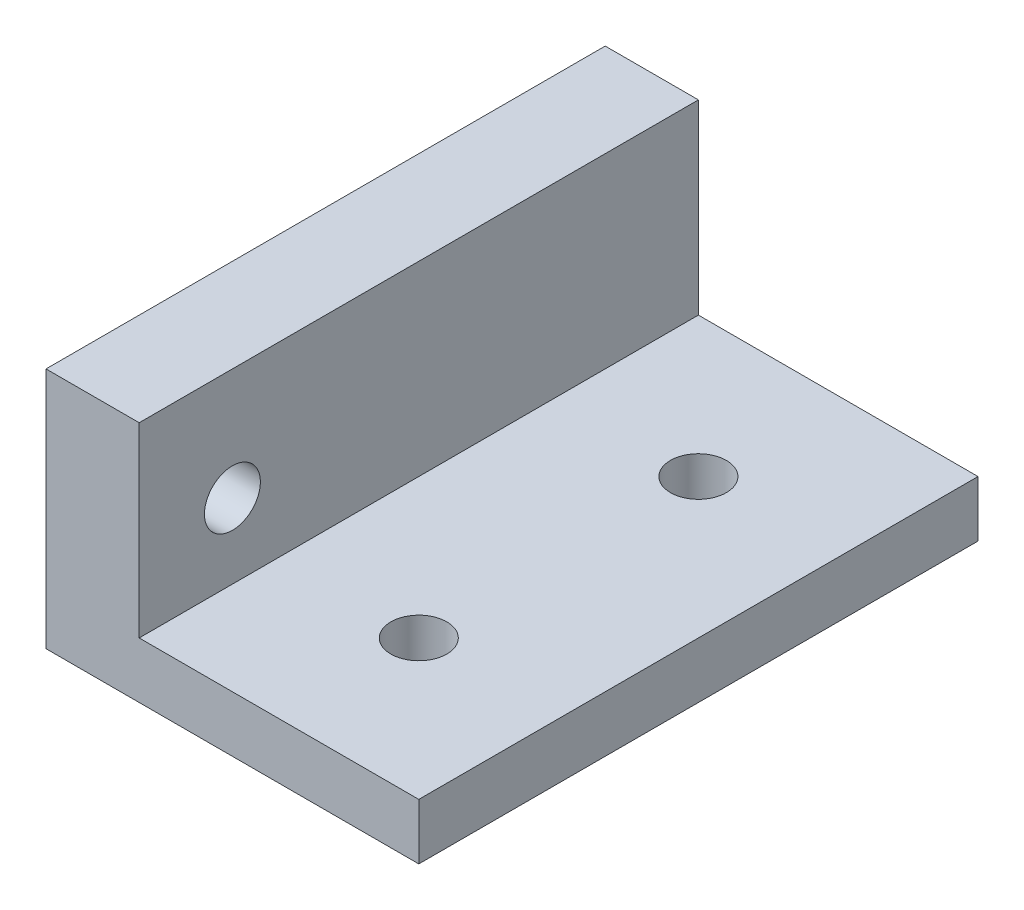
from build123d import *

# Parameters (mm, degrees)
SKETCH1_W           = 20
SKETCH1_H           = 30
BOSS_EXTRUDE1_DEPTH = 3
SKETCH2_W           = 5
SKETCH2_H           = 30
BOSS_EXTRUDE2_DEPTH = 10
SKETCH3_R           = 1.5
CUT_EXTRUDE1_DEPTH  = 10
SKETCH4_R           = 1.5
CUT_EXTRUDE2_DEPTH  = 4


with BuildPart() as part:
    # Sketch1 → Boss-Extrude1 (new body)
    with BuildSketch(Plane(origin=(0, 0, 0), x_dir=(1, 0, 0), z_dir=(0, 1, 0))):
        Rectangle(SKETCH1_W, SKETCH1_H)
    extrude(amount=BOSS_EXTRUDE1_DEPTH)

    # Sketch2 → Boss-Extrude2 (add)
    with BuildSketch(Plane(origin=(0, 3, 0), x_dir=(1, 0, 0), z_dir=(0, 1, 0))):
        with Locations((-7.5, 0)):
            Rectangle(SKETCH2_W, SKETCH2_H)
    extrude(amount=BOSS_EXTRUDE2_DEPTH)

    # Sketch3 → Cut-Extrude1 (cut)
    with BuildSketch(Plane.ZY.offset(10)):
        with Locations((10, 7)):
            Circle(SKETCH3_R)
    extrude(amount=-CUT_EXTRUDE1_DEPTH, mode=Mode.SUBTRACT)

    # Sketch4 → Cut-Extrude2 (cut, through all)
    with BuildSketch(Plane(origin=(0, 3, 0), x_dir=(1, 0, 0), z_dir=(0, 1, 0))):
        with Locations((2.5, -7.5)):
            Circle(SKETCH4_R)
        with Locations((2.5, 7.5)):
            Circle(SKETCH4_R)
    extrude(amount=-CUT_EXTRUDE2_DEPTH, mode=Mode.SUBTRACT)


solid = part.part
